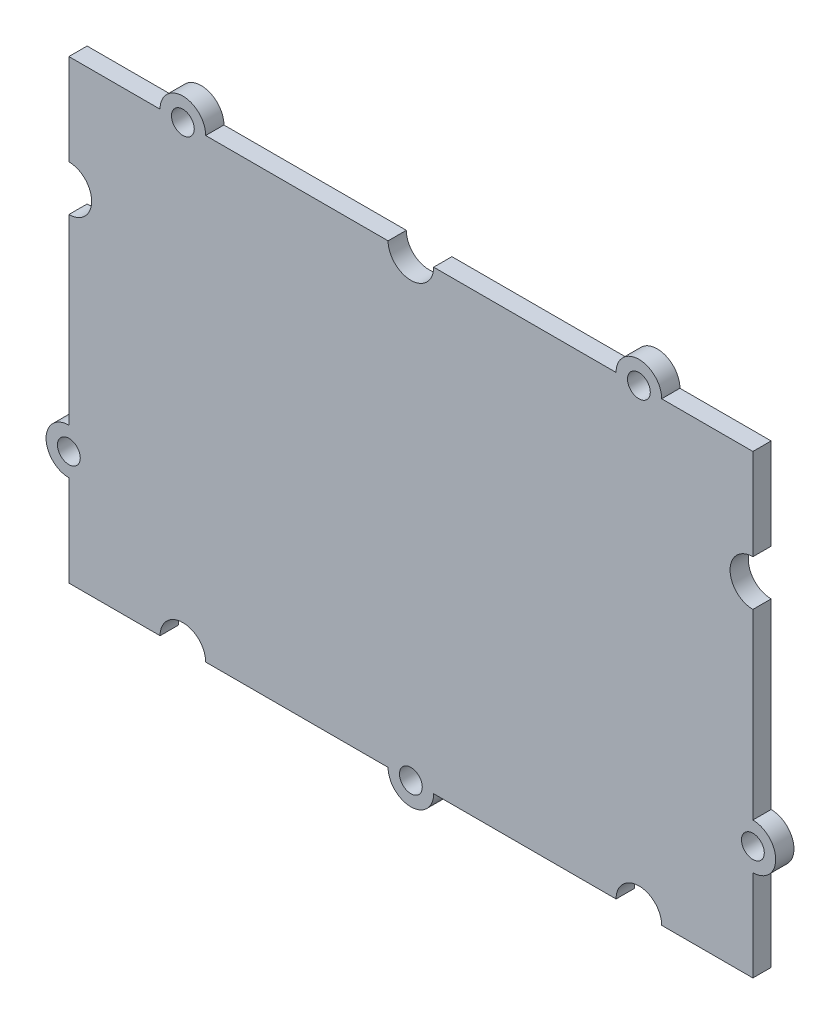
from build123d import *

# Parameters (mm, degrees)
ESQUISSE1_R        = 1
BOSS_EXTRU_1_DEPTH = 1.6


with BuildPart() as part:
    # Esquisse1 → Boss.-Extru.1 (new body)
    with BuildSketch(Plane.XY):
        with BuildLine():
            Line((-30, 8), (-30, -8))
            ThreePointArc((-30, -8), (-32, -10), (-30, -12))
            Line((-30, -12), (-30, -20))
            Line((-30, -20), (-22, -20))
            ThreePointArc((-22, -20), (-20, -18), (-18, -20))
            Line((-18, -20), (-2, -20))
            ThreePointArc((-2, -20), (0, -22), (2, -20))
            Line((2, -20), (18, -20))
            ThreePointArc((18, -20), (20, -18), (22, -20))
            Line((22, -20), (30, -20))
            Line((30, -20), (30, -12))
            ThreePointArc((30, -12), (32, -10), (30, -8))
            Line((30, -8), (30, 8))
            ThreePointArc((30, 8), (28, 10), (30, 12))
            Line((30, 12), (30, 20))
            Line((30, 20), (22, 20))
            ThreePointArc((22, 20), (20, 22), (18, 20))
            Line((18, 20), (2, 20))
            ThreePointArc((2, 20), (0, 18), (-2, 20))
            Line((-2, 20), (-18, 20))
            ThreePointArc((-18, 20), (-20, 22), (-22, 20))
            Line((-22, 20), (-30, 20))
            Line((-30, 20), (-30, 12))
            ThreePointArc((-30, 12), (-28, 10), (-30, 8))
        make_face()
        with Locations((-20, 20)):
            Circle(ESQUISSE1_R, mode=Mode.SUBTRACT)
        with Locations((20, 20)):
            Circle(ESQUISSE1_R, mode=Mode.SUBTRACT)
        with Locations((0, -20)):
            Circle(ESQUISSE1_R, mode=Mode.SUBTRACT)
        with Locations((-30, -10)):
            Circle(ESQUISSE1_R, mode=Mode.SUBTRACT)
        with Locations((30, -10)):
            Circle(ESQUISSE1_R, mode=Mode.SUBTRACT)
    extrude(amount=BOSS_EXTRU_1_DEPTH)


solid = part.part
